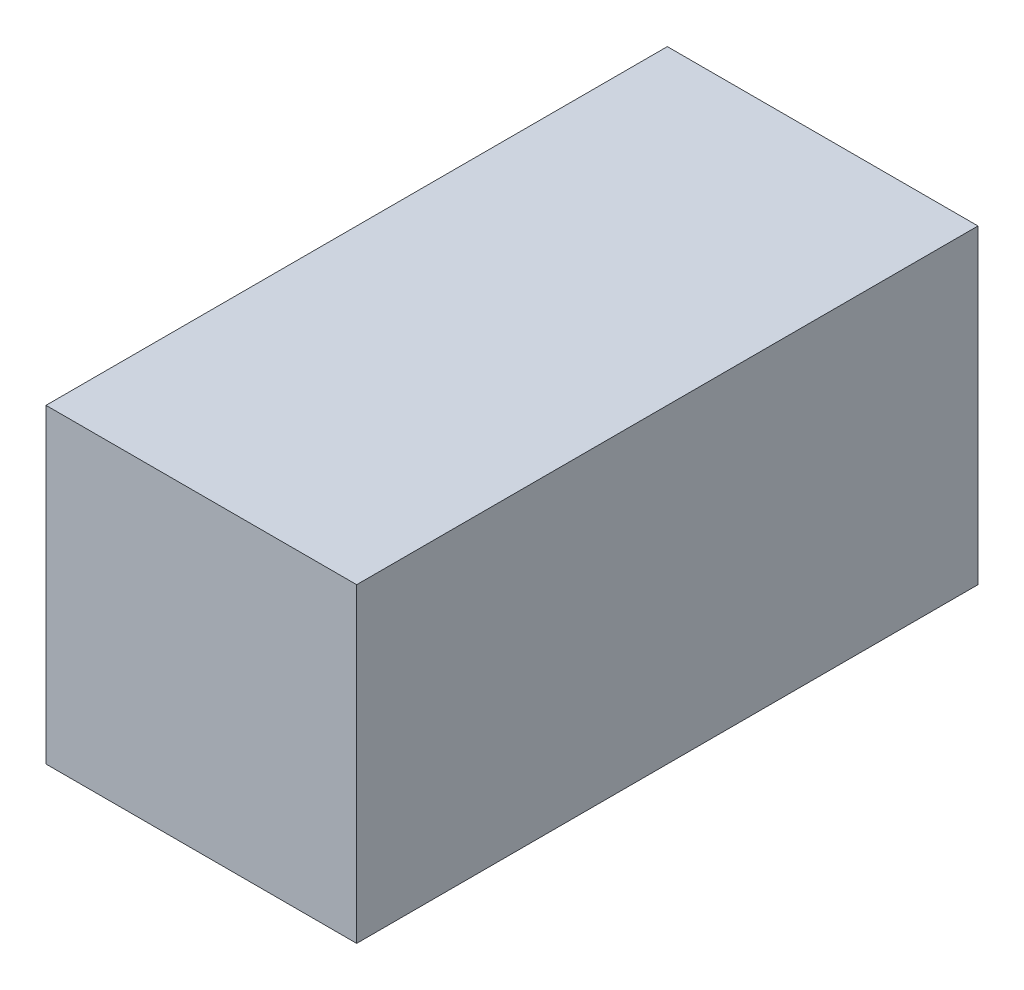
from build123d import *

# Parameters (mm, degrees)
SKETCH1_W      = 0.254
SKETCH1_H      = 0.254
EXTRUDE1_DEPTH = 0.254


with BuildPart() as part:
    # Sketch1 → Extrude1 (new body, symmetric)
    with BuildSketch(Plane.XY):
        with Locations((0, 0.127)):
            Rectangle(SKETCH1_W, SKETCH1_H)
    extrude(amount=EXTRUDE1_DEPTH, both=True)


solid = part.part
